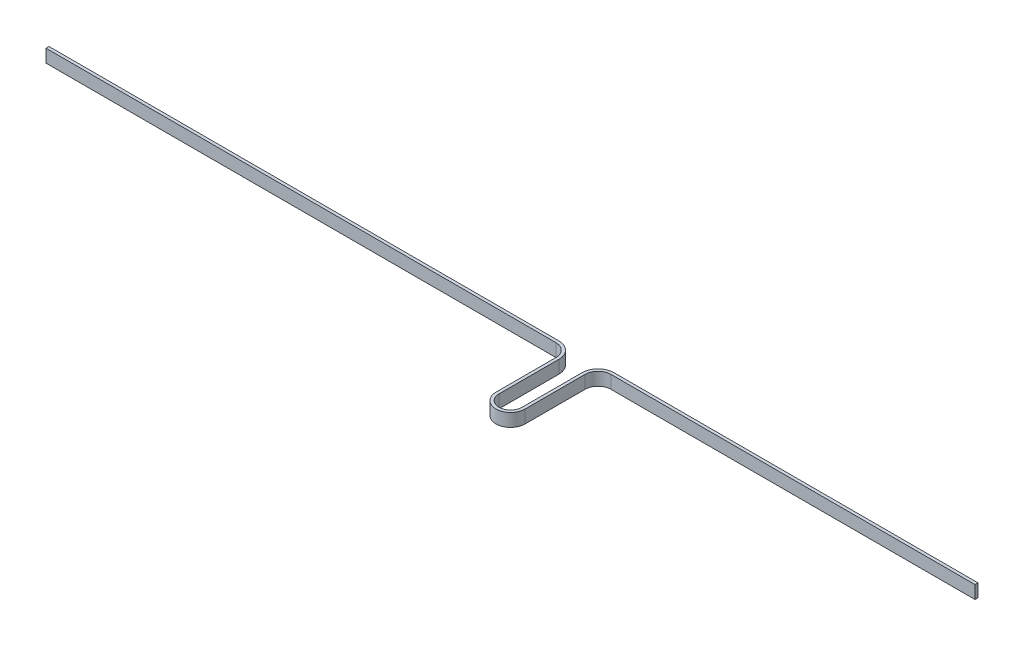
from build123d import *

# Parameters (mm, degrees)
EXTRUDE_THIN1_DEPTH = 6


with BuildPart() as part:
    # Sketch1 → Extrude-Thin1 (new body)
    with BuildSketch(Plane(origin=(0, 0, 0), x_dir=(1, 0, 0), z_dir=(0, 1, 0))):
        with BuildLine():
            Line((531.62539661, -259.643481844), (363.12, -259.643481844))
            ThreePointArc((363.12, -259.643481844), (357.905794596, -261.80327644), (355.746, -267.017481844))
            Line((355.746, -267.017481844), (355.746, -294.767481844))
            ThreePointArc((355.746, -294.767481844), (350.38, -300.133481844), (345.014, -294.767481844))
            Line((345.014, -294.767481844), (345.014, -267.017481844))
            ThreePointArc((345.014, -267.017481844), (342.854205404, -261.80327644), (337.64, -259.643481844))
            Line((337.64, -259.643481844), (101.625, -259.643481844))
            Line((101.625, -259.643481844), (101.625, -261.023481844))
            Line((101.625, -261.023481844), (337.64, -261.023481844))
            ThreePointArc((337.64, -261.023481844), (341.878398046, -262.779083798), (343.634, -267.017481844))
            Line((343.634, -267.017481844), (343.634, -294.767481844))
            ThreePointArc((343.634, -294.767481844), (350.38, -301.513481844), (357.126, -294.767481844))
            Line((357.126, -294.767481844), (357.126, -267.017481844))
            ThreePointArc((357.126, -267.017481844), (358.881601954, -262.779083798), (363.12, -261.023481844))
            Line((363.12, -261.023481844), (531.62539661, -261.023481844))
            Line((531.62539661, -261.023481844), (531.62539661, -259.643481844))
        make_face()
    extrude(amount=EXTRUDE_THIN1_DEPTH)


solid = part.part
